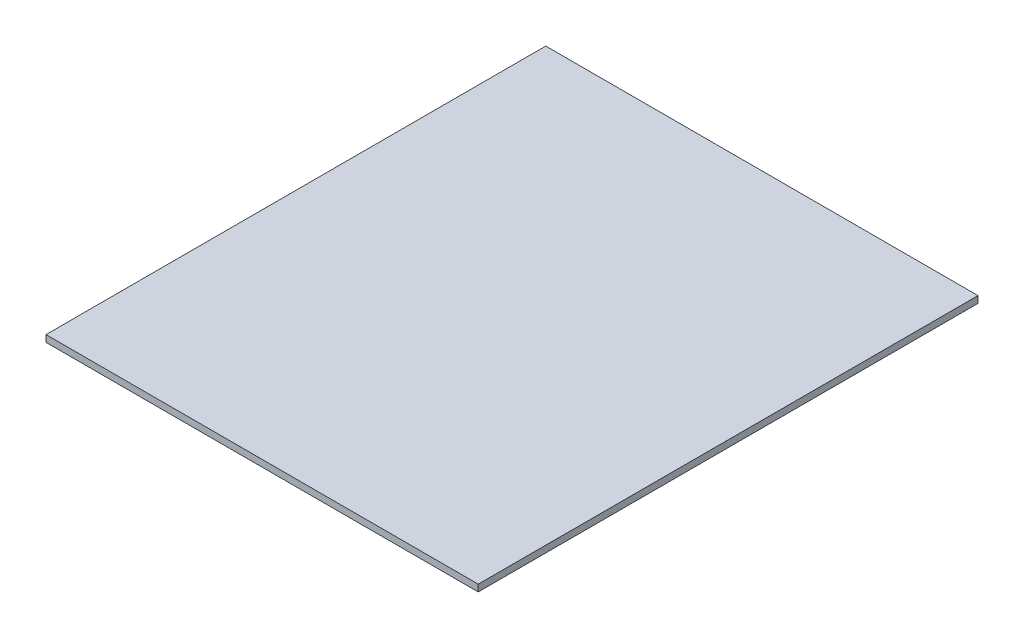
from build123d import *

# Parameters (mm, degrees)
BOSS_EXTRUDE1_DEPTH = 10


with BuildPart() as part:
    # 3DSketch1 → Boss-Extrude1 (new body)
    with BuildSketch(Plane(origin=(441.943070464, 263.611721566, 236.005582996), x_dir=(-0.6541519329315842, 0, -0.7563631724521444), z_dir=(0, 1, 0))):
        Polygon((0, 0), (418.657237076, 484.072430369), (978.365984691, 0), (559.708747615, -484.072430369), align=None)
    extrude(amount=BOSS_EXTRUDE1_DEPTH)


solid = part.part
